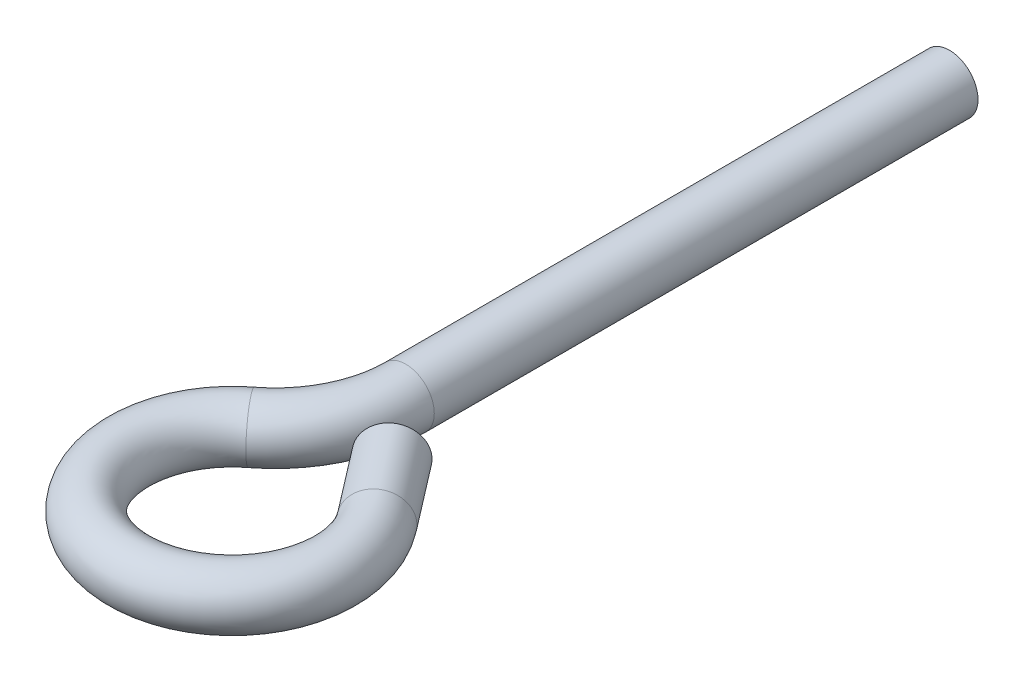
from build123d import *

# Parameters (mm, degrees)
SKETCH1_R           = 2.667
BOSS_EXTRUDE1_DEPTH = 50.8
SKETCH2_R           = 2.667
REVOLVE1_ANGLE      = 52.5
SKETCH3_R           = 2.667
REVOLVE2_ANGLE      = 270
SKETCH4_R           = 2.667
BOSS_EXTRUDE2_DEPTH = 7.62


with BuildPart() as part:
    # Sketch1 → Boss-Extrude1 (new body)
    with BuildSketch(Plane.XY):
        Circle(SKETCH1_R)
    extrude(amount=BOSS_EXTRUDE1_DEPTH)

    # Sketch2 → Revolve1 (revolve)
    with BuildSketch(Plane.XY.offset(50.8)):
        Circle(SKETCH2_R)
    revolve(axis=Axis((-12.192, -2.667, 50.8), (0, -1, 0)), revolution_arc=REVOLVE1_ANGLE)

    # Sketch3 → Revolve2 (revolve)
    with BuildSketch(Plane(origin=(-32.208276887, 0, 24.714280091), x_dir=(0.608761429, 0, 0.79335334), z_dir=(-0.79335334, 0, 0.608761429))):
        with Locations((45.072330344, 0)):
            Circle(SKETCH3_R)
    revolve(axis=Axis((1.105784655, -2.667, 68.130010365), (0, 1, 0)), revolution_arc=REVOLVE2_ANGLE)

    # Sketch4 → Boss-Extrude2 (add)
    with BuildSketch(Plane(origin=(33.314061542, 0, 43.415730274), x_dir=(-0.79335334, 0, 0.608761429), z_dir=(-0.608761429, 0, -0.79335334))):
        with Locations((30.945644518, 0)):
            Circle(SKETCH4_R)
    extrude(amount=BOSS_EXTRUDE2_DEPTH)


solid = part.part
